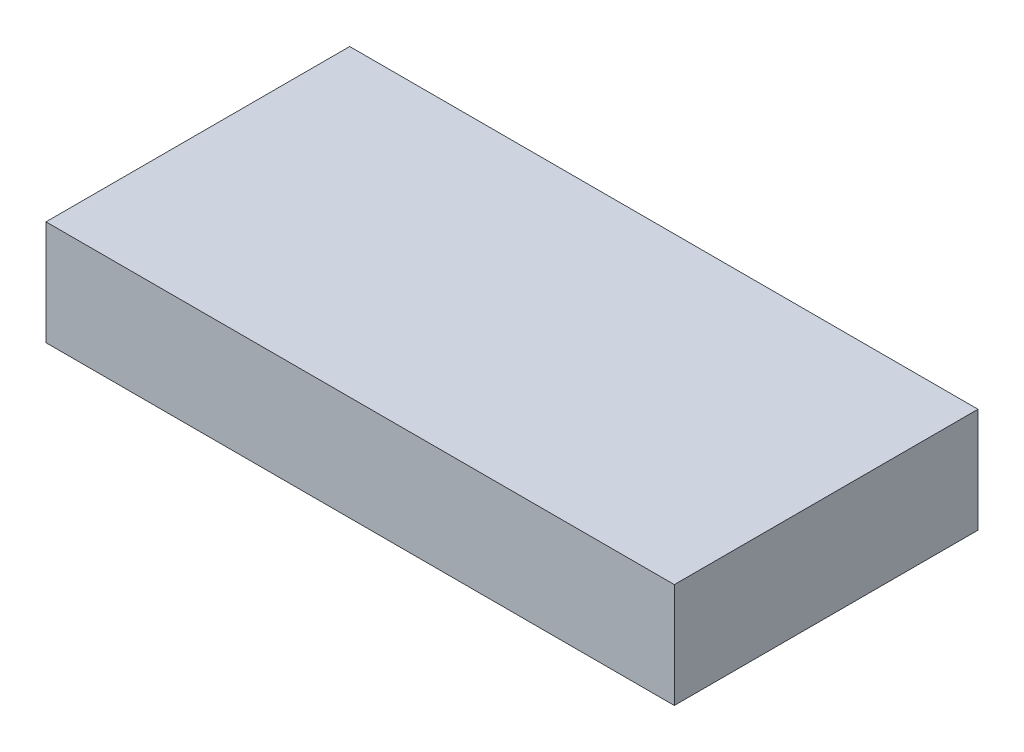
from build123d import *

# Parameters (mm, degrees)
SKETCH1_W           = 30
SKETCH1_H           = 14.5
BOSS_EXTRUDE1_DEPTH = 5


with BuildPart() as part:
    # Sketch1 → Boss-Extrude1 (new body)
    with BuildSketch(Plane(origin=(0, 0, 0), x_dir=(1, 0, 0), z_dir=(0, 1, 0))):
        with Locations((15, 7.25)):
            Rectangle(SKETCH1_W, SKETCH1_H)
    extrude(amount=BOSS_EXTRUDE1_DEPTH)


solid = part.part
